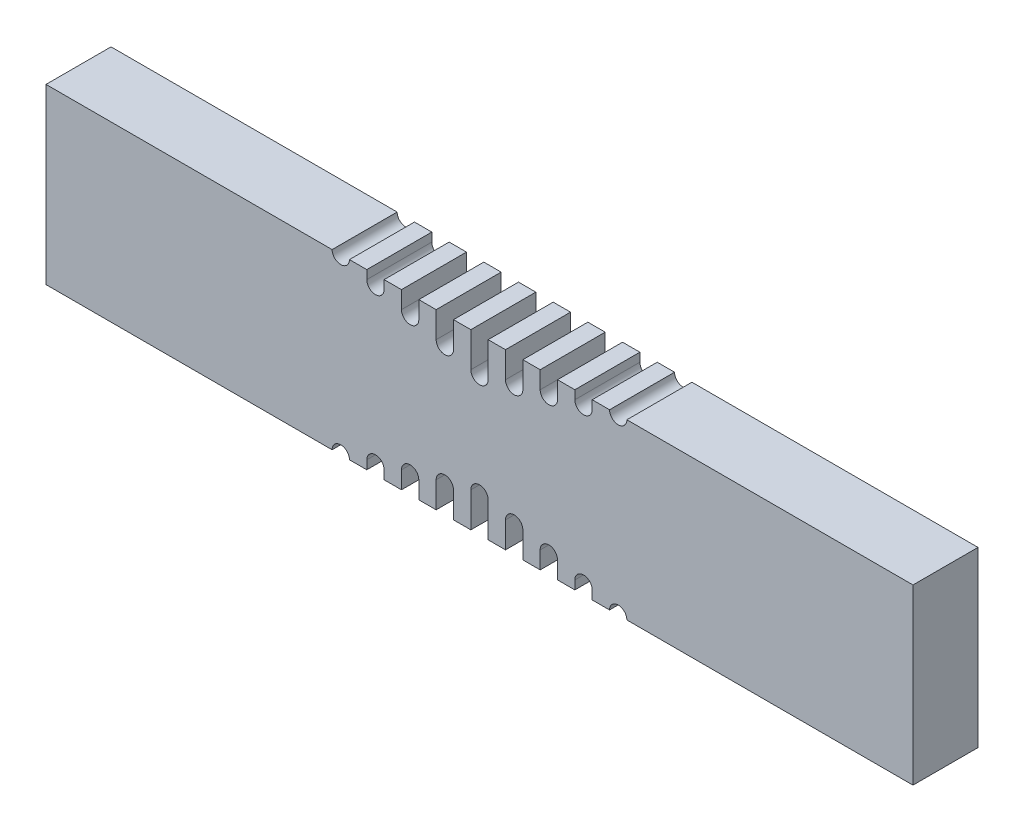
from build123d import *

# Parameters (mm, degrees)
SKETCH1_W                                = 200
SKETCH1_H                                = 40
RECTANGULAR_BAR_40_W_X_200_L_X_15D_DEPTH = 15
NOTCH_CUT_OUT_DEPTH                      = 15
CUT_EXTRUDE1_DEPTH                       = 16


with BuildPart() as part:
    # Sketch1 → Rectangular Bar (40 W x 200 L x 15D) (new body)
    with BuildSketch(Plane.XY):
        Rectangle(SKETCH1_W, SKETCH1_H)
    extrude(amount=RECTANGULAR_BAR_40_W_X_200_L_X_15D_DEPTH)

    # Notch → Notch cut out (cut)
    with BuildSketch(Plane.XY.offset(15)):
        with BuildLine():
            Line((2, 20), (2, 12))
            ThreePointArc((2, 12), (0, 10), (-2, 12))
            Line((-2, 12), (-2, 20))
            Line((-2, 20), (2, 20))
        make_face()
        with BuildLine():
            Line((-2, -20), (-2, -12))
            ThreePointArc((-2, -12), (0, -10), (2, -12))
            Line((2, -12), (2, -20))
            Line((2, -20), (-2, -20))
        make_face()
    extrude(amount=-NOTCH_CUT_OUT_DEPTH, mode=Mode.SUBTRACT)

    # Sketch2 → Cut-Extrude1 (cut, through all)
    with BuildSketch(Plane.XY.offset(15)):
        with BuildLine():
            Line((6, 20), (6, 14))
            ThreePointArc((6, 14), (8, 12), (10, 14))
            Line((10, 14), (10, 20))
            Line((10, 20), (6, 20))
        make_face()
        with BuildLine():
            Line((14, 20), (14, 16))
            ThreePointArc((14, 16), (16, 14), (18, 16))
            Line((18, 16), (18, 20))
            Line((18, 20), (14, 20))
        make_face()
        with BuildLine():
            Line((22, 20), (22, 18))
            ThreePointArc((22, 18), (24, 16), (26, 18))
            Line((26, 18), (26, 20))
            Line((26, 20), (22, 20))
        make_face()
        with BuildLine():
            Line((30, 20), (34, 20))
            ThreePointArc((34, 20), (32, 18), (30, 20))
        make_face()
        with BuildLine():
            Line((-30, 20), (-34, 20))
            ThreePointArc((-34, 20), (-32, 18), (-30, 20))
        make_face()
        with BuildLine():
            Line((-22, 20), (-26, 20))
            Line((-26, 20), (-26, 18))
            ThreePointArc((-26, 18), (-24, 16), (-22, 18))
            Line((-22, 18), (-22, 20))
        make_face()
        with BuildLine():
            Line((-18, 20), (-18, 16))
            ThreePointArc((-18, 16), (-16, 14), (-14, 16))
            Line((-14, 16), (-14, 20))
            Line((-14, 20), (-18, 20))
        make_face()
        with BuildLine():
            Line((-10, 20), (-10, 14))
            ThreePointArc((-10, 14), (-8, 12), (-6, 14))
            Line((-6, 14), (-6, 20))
            Line((-6, 20), (-10, 20))
        make_face()
        with BuildLine():
            Line((30, -20), (34, -20))
            ThreePointArc((34, -20), (32, -18), (30, -20))
        make_face()
        with BuildLine():
            Line((26, -20), (26, -18))
            ThreePointArc((26, -18), (24, -16), (22, -18))
            Line((22, -18), (22, -20))
            Line((22, -20), (26, -20))
        make_face()
        with BuildLine():
            Line((18, -20), (18, -16))
            ThreePointArc((18, -16), (16, -14), (14, -16))
            Line((14, -16), (14, -20))
            Line((14, -20), (18, -20))
        make_face()
        with BuildLine():
            Line((10, -20), (10, -14))
            ThreePointArc((10, -14), (8, -12), (6, -14))
            Line((6, -14), (6, -20))
            Line((6, -20), (10, -20))
        make_face()
        with BuildLine():
            Line((-6, -20), (-6, -14))
            ThreePointArc((-6, -14), (-8, -12), (-10, -14))
            Line((-10, -14), (-10, -20))
            Line((-10, -20), (-6, -20))
        make_face()
        with BuildLine():
            Line((-14, -20), (-14, -16))
            ThreePointArc((-14, -16), (-16, -14), (-18, -16))
            Line((-18, -16), (-18, -20))
            Line((-18, -20), (-14, -20))
        make_face()
        with BuildLine():
            Line((-30, -20), (-34, -20))
            ThreePointArc((-34, -20), (-32, -18), (-30, -20))
        make_face()
        with BuildLine():
            Line((-22, -20), (-22, -18))
            ThreePointArc((-22, -18), (-24, -16), (-26, -18))
            Line((-26, -18), (-26, -20))
            Line((-26, -20), (-22, -20))
        make_face()
    extrude(amount=-CUT_EXTRUDE1_DEPTH, mode=Mode.SUBTRACT)


solid = part.part
